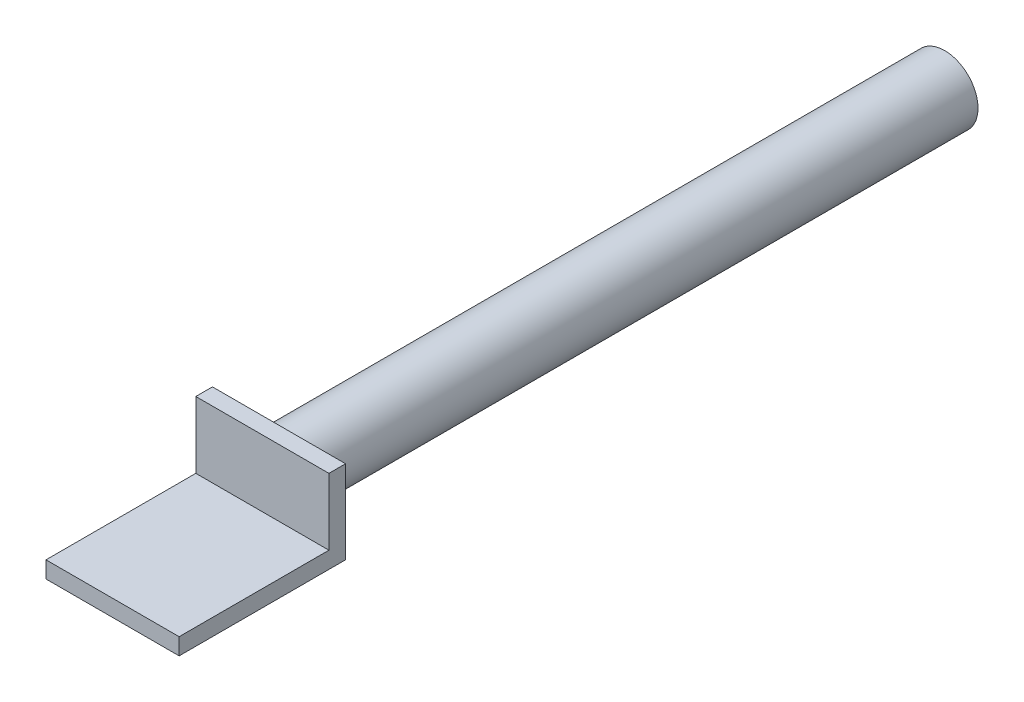
from build123d import *

# Parameters (mm, degrees)
SKETCH1_R           = 12.7
BOSS_EXTRUDE1_DEPTH = 254
SKETCH2_W           = 50.8
SKETCH2_H           = 31.75
BOSS_EXTRUDE2_DEPTH = 63.5
CUT_EXTRUDE1_REACH  = 52.8
SKETCH3_W           = 57.15
SKETCH3_H           = 25.4


with BuildPart() as part:
    # Sketch1 → Boss-Extrude1 (new body)
    with BuildSketch(Plane.XY):
        Circle(SKETCH1_R)
    extrude(amount=BOSS_EXTRUDE1_DEPTH)

    # Sketch2 → Boss-Extrude2 (add)
    with BuildSketch(Plane.XY.offset(254)):
        Rectangle(SKETCH2_W, SKETCH2_H)
    extrude(amount=BOSS_EXTRUDE2_DEPTH)

    # Sketch3 → Cut-Extrude1 (cut, up to next)
    with BuildSketch(Plane(origin=(25.4, 0, 0), x_dir=(0, 0, -1), z_dir=(1, 0, 0)), mode=Mode.PRIVATE) as cut_extrude1_sk1:
        with Locations((-288.925, 3.175)):
            Rectangle(SKETCH3_W, SKETCH3_H)
    cut_extrude1_tool1 = extrude(cut_extrude1_sk1.sketch, amount=-CUT_EXTRUDE1_REACH, mode=Mode.PRIVATE) & part.part
    add(cut_extrude1_tool1.solids().sort_by_distance((25.4, 3.175, 288.925))[0], mode=Mode.SUBTRACT)


solid = part.part
